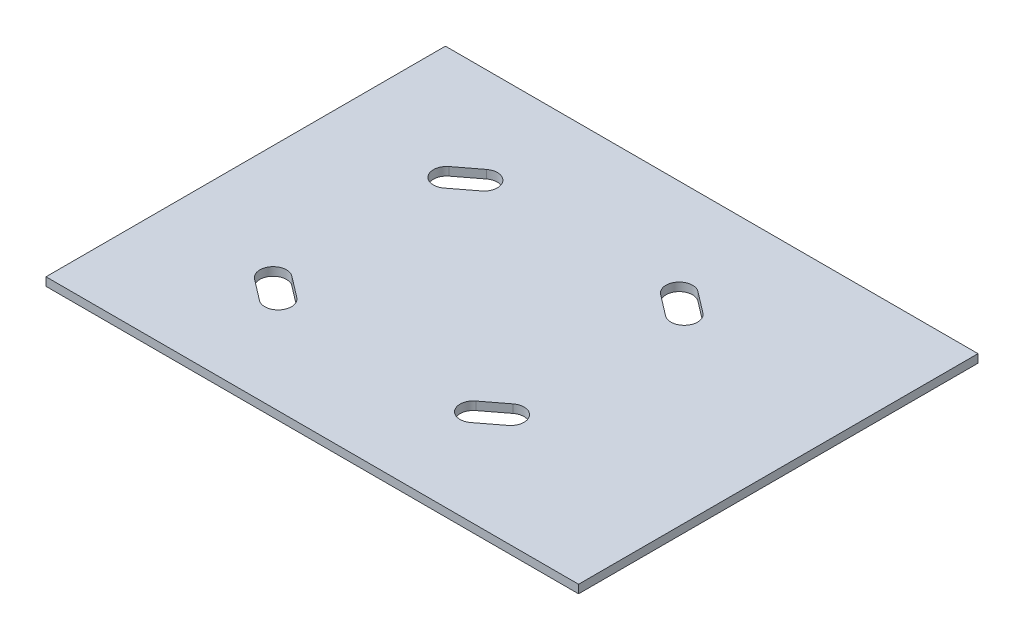
from build123d import *

# Parameters (mm, degrees)
SKETCH1_W           = 203.2
SKETCH1_H           = 152.4
BOSS_EXTRUDE1_DEPTH = 3.175


with BuildPart() as part:
    # Sketch1 → Boss-Extrude1 (new body)
    with BuildSketch(Plane(origin=(0, 0, 0), x_dir=(1, 0, 0), z_dir=(0, 1, 0))):
        with Locations((12.7, 0)):
            Rectangle(SKETCH1_W, SKETCH1_H)
        with BuildLine():
            Line((-48.396184338, 37.144491245), (-40.325508755, 43.316184338))
            ThreePointArc((-40.325508755, 43.316184338), (-33.204324417, 42.366693093), (-34.153815662, 35.245508755))
            Line((-34.153815662, 35.245508755), (-42.224491245, 29.073815662))
            ThreePointArc((-42.224491245, 29.073815662), (-49.345675583, 30.023306907), (-48.396184338, 37.144491245))
        make_face(mode=Mode.SUBTRACT)
        with BuildLine():
            Line((34.153815662, 35.245508755), (42.224491245, 29.073815662))
            ThreePointArc((42.224491245, 29.073815662), (49.345675583, 30.023306907), (48.396184338, 37.144491245))
            Line((48.396184338, 37.144491245), (40.325508755, 43.316184338))
            ThreePointArc((40.325508755, 43.316184338), (33.204324417, 42.366693093), (34.153815662, 35.245508755))
        make_face(mode=Mode.SUBTRACT)
        with BuildLine():
            Line((34.153815662, -35.245508755), (42.224491245, -29.073815662))
            ThreePointArc((42.224491245, -29.073815662), (49.345675583, -30.023306907), (48.396184338, -37.144491245))
            Line((48.396184338, -37.144491245), (40.325508755, -43.316184338))
            ThreePointArc((40.325508755, -43.316184338), (33.204324417, -42.366693093), (34.153815662, -35.245508755))
        make_face(mode=Mode.SUBTRACT)
        with BuildLine():
            Line((-48.396184338, -37.144491245), (-40.325508755, -43.316184338))
            ThreePointArc((-40.325508755, -43.316184338), (-33.204324417, -42.366693093), (-34.153815662, -35.245508755))
            Line((-34.153815662, -35.245508755), (-42.224491245, -29.073815662))
            ThreePointArc((-42.224491245, -29.073815662), (-49.345675583, -30.023306907), (-48.396184338, -37.144491245))
        make_face(mode=Mode.SUBTRACT)
    extrude(amount=BOSS_EXTRUDE1_DEPTH)


solid = part.part
